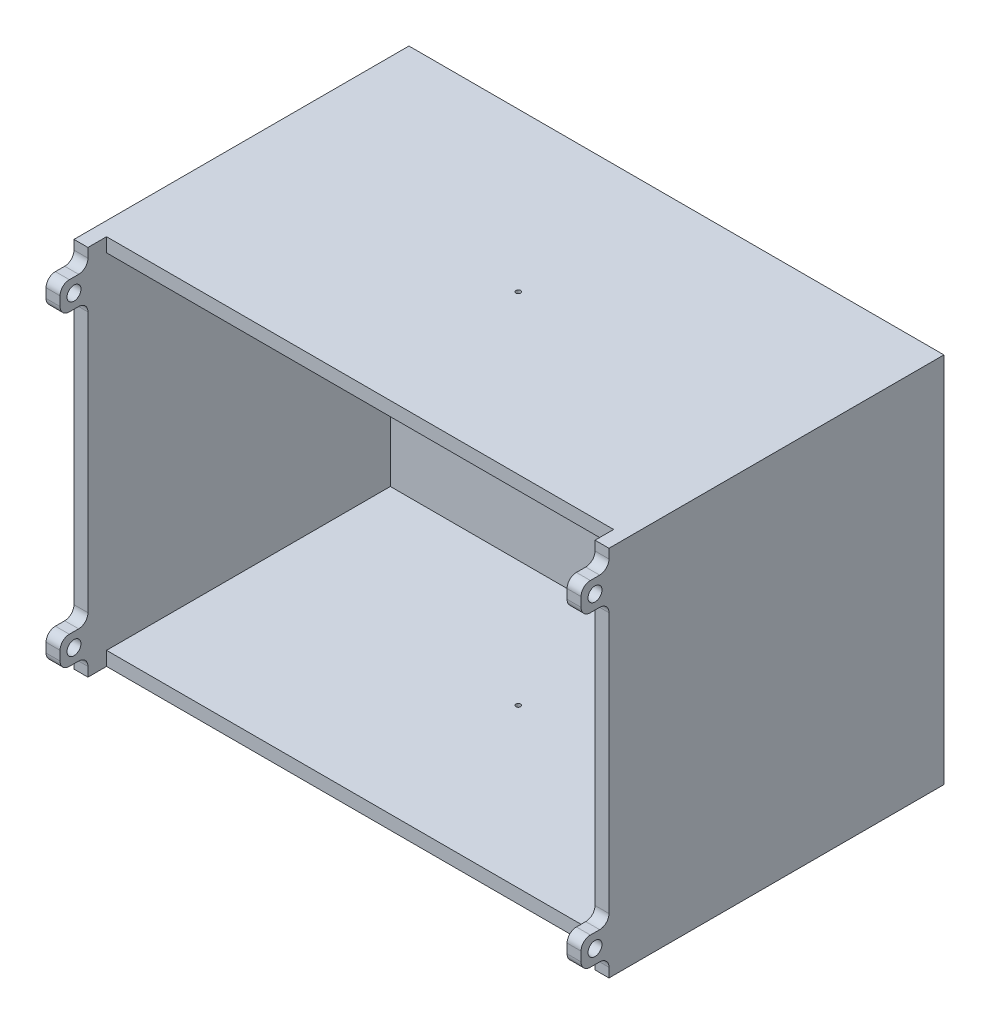
from build123d import *

# Parameters (mm, degrees)
SKETCH1_W               = 80
SKETCH1_H               = 115
BOSS_EXTRUDE1_DEPTH     = 72
SKETCH3_W               = 109
SKETCH3_H               = 74
CUT_EXTRUDE1_DEPTH      = 1
CUT_EXTRUDE1_DEPTH_BACK = 65
SKETCH4_W               = 3
SKETCH4_H               = 6
BOSS_EXTRUDE2_DEPTH     = 6
SKETCH5_W               = 109
SKETCH5_H               = 3
CUT_EXTRUDE2_DEPTH      = 4
SKETCH6_R               = 1.5
CUT_EXTRUDE3_DEPTH      = 1
CUT_EXTRUDE3_DEPTH_BACK = 116
FILLET1_R               = 2
SKETCH7_R               = 0.5
CUT_EXTRUDE4_DEPTH      = 1
CUT_EXTRUDE4_DEPTH_BACK = 81


with BuildPart() as part:
    # Sketch1 → Boss-Extrude1 (new body)
    with BuildSketch(Plane(origin=(0, 0, 0), x_dir=(0, 1, 0), z_dir=(0, 0, 1))):
        Rectangle(SKETCH1_W, SKETCH1_H)
    extrude(amount=BOSS_EXTRUDE1_DEPTH)

    # Sketch3 → Cut-Extrude1 (cut, two sides)
    with BuildSketch(Plane.XY.offset(72)) as cut_extrude1_sk:
        Rectangle(SKETCH3_W, SKETCH3_H)
    extrude(amount=CUT_EXTRUDE1_DEPTH, mode=Mode.SUBTRACT)
    extrude(cut_extrude1_sk.sketch, amount=-CUT_EXTRUDE1_DEPTH_BACK, mode=Mode.SUBTRACT)

    # Sketch4 → Boss-Extrude2 (add)
    with BuildSketch(Plane.XY.offset(72)):
        with Locations((-56, 33)):
            Rectangle(SKETCH4_W, SKETCH4_H)
        with Locations((-56, -33)):
            Rectangle(SKETCH4_W, SKETCH4_H)
        with Locations((56, -33)):
            Rectangle(SKETCH4_W, SKETCH4_H)
        with Locations((56, 33)):
            Rectangle(SKETCH4_W, SKETCH4_H)
    extrude(amount=BOSS_EXTRUDE2_DEPTH)

    # Sketch5 → Cut-Extrude2 (cut)
    with BuildSketch(Plane.XY.offset(72)):
        with Locations((0, 38.5)):
            Rectangle(SKETCH5_W, SKETCH5_H)
        with Locations((0, -38.5)):
            Rectangle(SKETCH5_W, SKETCH5_H)
    extrude(amount=-CUT_EXTRUDE2_DEPTH, mode=Mode.SUBTRACT)

    # Sketch6 → Cut-Extrude3 (cut, two sides)
    with BuildSketch(Plane.YZ.offset(57.5)) as cut_extrude3_sk:
        with Locations((-33, 75)):
            Circle(SKETCH6_R)
        with Locations((33, 75)):
            Circle(SKETCH6_R)
    extrude(amount=CUT_EXTRUDE3_DEPTH, mode=Mode.SUBTRACT)
    extrude(cut_extrude3_sk.sketch, amount=-CUT_EXTRUDE3_DEPTH_BACK, mode=Mode.SUBTRACT)

    # Fillet1
    fillet1_edges = [part.edges().sort_by_distance(p)[0] for p in [
        (56, 30, 72),
        (56, 36, 72),
        (56, 30, 78),
        (56, 36, 78),
        (56, -36, 72),
        (56, -30, 72),
        (56, -36, 78),
        (56, -30, 78),
        (-56, -30, 72),
        (-56, -36, 72),
        (-56, -30, 78),
        (-56, -36, 78),
        (-56, 36, 72),
        (-56, 30, 72),
        (-56, 36, 78),
        (-56, 30, 78),
    ]]
    fillet(fillet1_edges, radius=FILLET1_R)

    # Sketch7 → Cut-Extrude4 (cut, two sides)
    with BuildSketch(Plane(origin=(0, 40, 0), x_dir=(-1, 0, 0), z_dir=(0, 1, 0))) as cut_extrude4_sk:
        with Locations((0, 34)):
            Circle(SKETCH7_R)
    extrude(amount=CUT_EXTRUDE4_DEPTH, mode=Mode.SUBTRACT)
    extrude(cut_extrude4_sk.sketch, amount=-CUT_EXTRUDE4_DEPTH_BACK, mode=Mode.SUBTRACT)


solid = part.part
